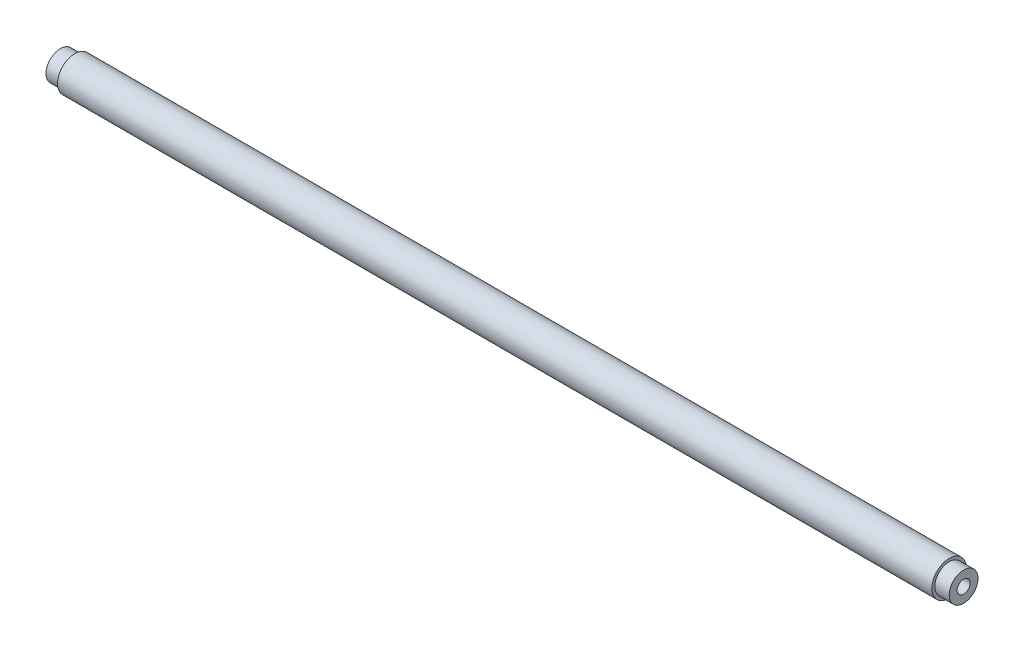
from build123d import *


with BuildPart() as part:
    # Çizim1 → Döndür1 (revolve)
    with BuildSketch(Plane.XY):
        Polygon((-235, 0), (235, 0), (235, 7.5), (227.5, 7.5), (227.5, 9), (-227.5, 9), (-227.5, 7.5), (-235, 7.5), align=None)
    revolve(axis=Axis((-235, 0, 0), (1, 0, 0)))

    # Çizim3 → M8 Dişli Delik1 (revolve, cut)
    with BuildSketch(Plane(origin=(235, 0, 0), x_dir=(0, 0, -1), z_dir=(0, 1, 0))):
        Polygon((0, 0), (0, 22.042926105), (3.4, 20), (3.4, 0), align=None)
    m8_di_li_delik1 = revolve(axis=Axis((241.35, 0, 0), (-1, 0, 0)), mode=Mode.SUBTRACT)

    # Aynalama1: M8 Dişli Delik1 across plane
    add(m8_di_li_delik1.mirror(Plane(origin=(0, 0, 0), x_dir=(0, 0, 1), z_dir=(1, 0, 0))), mode=Mode.SUBTRACT)


solid = part.part
